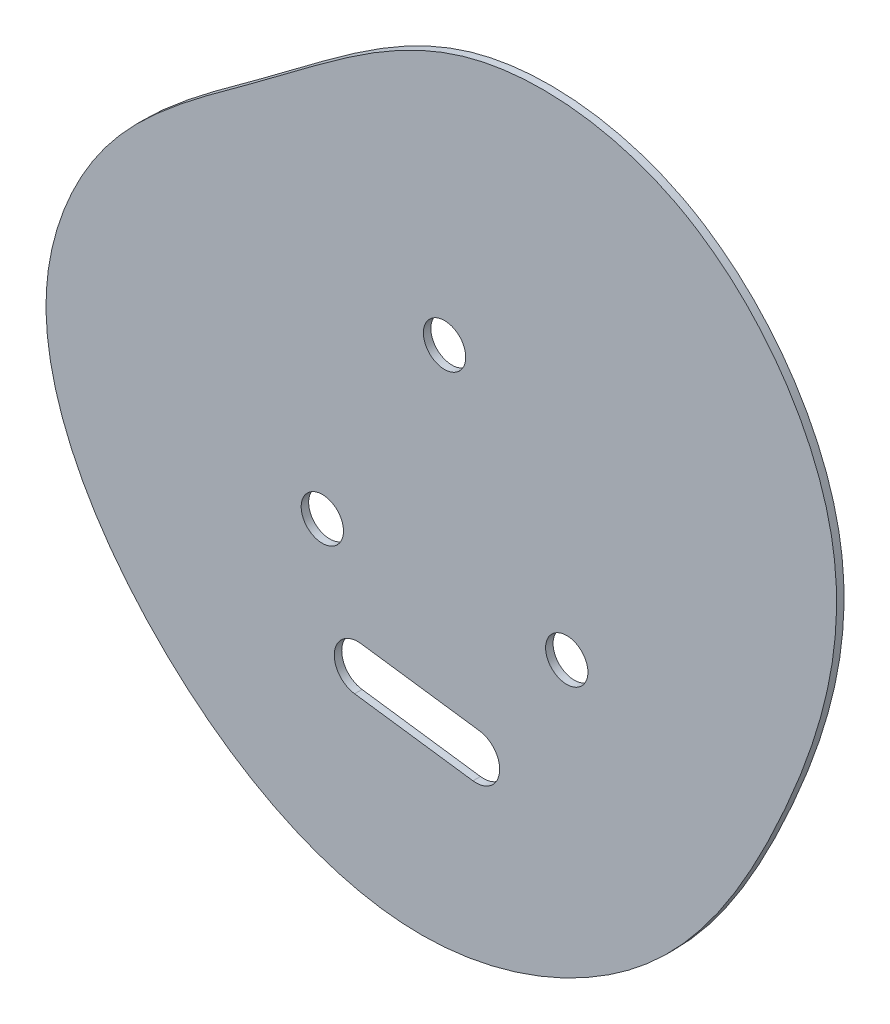
from build123d import *

# Parameters (mm, degrees)
BOSS_EXTRUDE1_DEPTH     = 0.396875
M4_CLEARANCE_HOLE1_D    = 4.5
CUT_EXTRUDE1_DEPTH      = 1.0000001
CUT_EXTRUDE1_DEPTH_BACK = 1.7937501


with BuildPart() as part:
    # Sketch1 → Boss-Extrude1 (new body, symmetric)
    with BuildSketch(Plane.XY):
        with BuildLine():
            add(Edge.make_bspline(
                [(11.938662052, 24.118546546), (5.203644407, 27.612099202), (-12.247017435, 29.216761409), (-30.839497435, 13.610185149), (-49.30348402, 1.488634449), (-58.548601808, -21.664446949), (-44.411240616, -46.56150278), (-17.228511826, -61.144878254), (10.679925614, -49.692920857), (24.553698364, -26.479665335), (33.387137292, 1.683714683), (20.41654036, 19.720946445), (11.938662052, 24.118546546)],
                knots=[0, 0, 0, 0, 0.086512684, 0.186061085, 0.27498958, 0.344292202, 0.456117157, 0.576745766, 0.675937244, 0.775538108, 0.891099913, 1, 1, 1, 1], degree=3))
        make_face()
    extrude(amount=BOSS_EXTRUDE1_DEPTH, both=True)

    # M4 Clearance Hole1 (through all)
    with Locations(Plane.XY.offset(0.396875)):
        with Locations((-12.593900177, -1.272585975), (0.396480879, -23.772585975), (-25.584281234, -23.772585975)):
            Hole(M4_CLEARANCE_HOLE1_D / 2)

    # Sketch8 → Cut-Extrude1 (cut, two sides)
    with BuildSketch(Plane.XY.offset(0.396875)) as cut_extrude1_sk:
        with BuildLine():
            Line((-21.476274898, -33.202714717), (-8.89395292, -34.927583887))
            ThreePointArc((-8.89395292, -34.927583887), (-6.756659061, -37.743960097), (-9.573035271, -39.881253957))
            Line((-9.573035271, -39.881253957), (-22.155357248, -38.156384786))
            ThreePointArc((-22.155357248, -38.156384786), (-24.292651108, -35.340008576), (-21.476274898, -33.202714717))
        make_face()
    extrude(amount=CUT_EXTRUDE1_DEPTH, mode=Mode.SUBTRACT)
    extrude(cut_extrude1_sk.sketch, amount=-CUT_EXTRUDE1_DEPTH_BACK, mode=Mode.SUBTRACT)


solid = part.part
